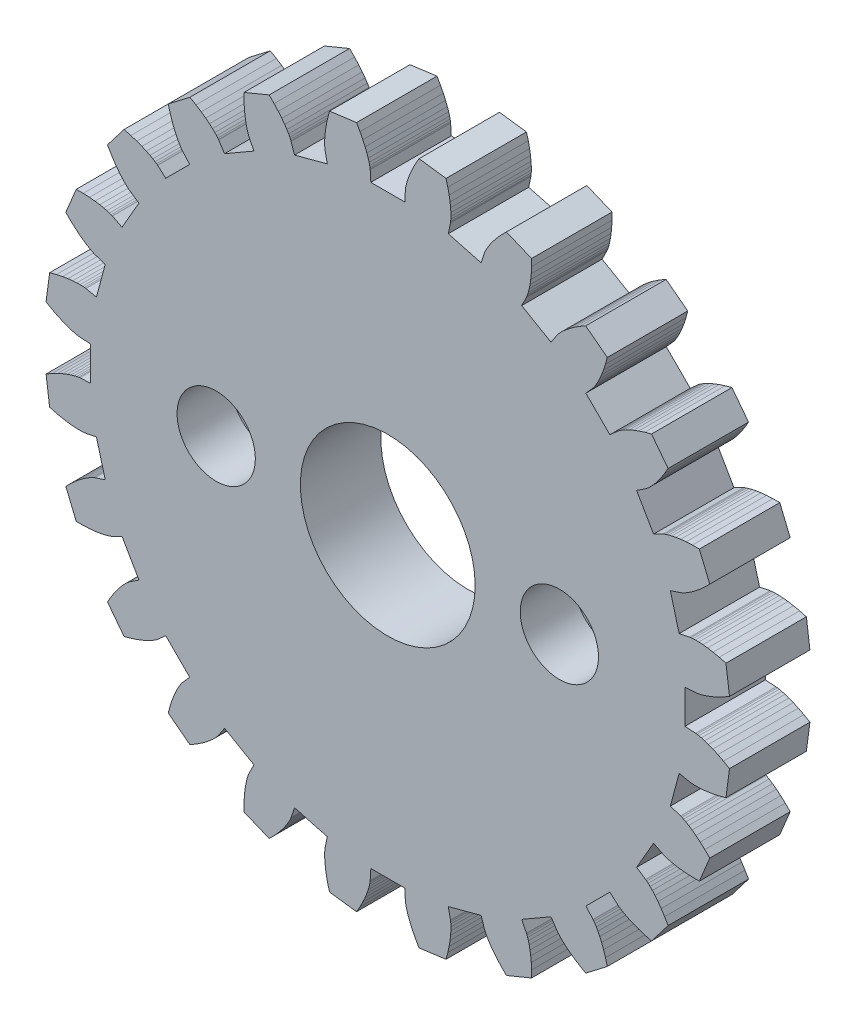
from build123d import *

# Parameters (mm, degrees)
MAIN_GEAR_BODY_DEPTH      = 3
SCALE1_SCALE              = 1.25
SKETCH1_R                 = 4.075
SKETCH1_R_2               = 1.15
SERVO_CLEARANCE_DEPTH     = 4.75
SKETCH2_R                 = 1.825
BOLT_HEAD_CLEARANCE_DEPTH = 2.5


with BuildPart() as part:
    # Model → Main Gear Body (new body)
    with BuildSketch(Plane.XY):
        Polygon((11.481280763, -0.655890262), (11.081931867, -0.633076687), (11.081931867, 0.633076687), (11.481280763, 0.655890262), (11.494959484, 0.657119822), (11.535795525, 0.662587053), (11.603342457, 0.674939875), (11.696960474, 0.69678954), (11.81581907, 0.730698092), (11.958900465, 0.779166001), (12.125003794, 0.844620031), (12.312750022, 0.929401369), (12.520587586, 1.035754071), (12.746798737, 1.165813859), (12.614196933, 2.173024562), (12.36203179, 2.240104916), (12.133750014, 2.289041418), (11.930458058, 2.322341602), (11.753073814, 2.342574636), (11.602323381, 2.352358851), (11.478738615, 2.354349128), (11.382655444, 2.351224158), (11.314212973, 2.345673635), (11.273353363, 2.34038543), (11.259822499, 2.338032781), (10.868176499, 2.256709902), (10.540471892, 3.479720146), (10.920308717, 3.605115467), (10.933203113, 3.609843444), (10.971232676, 3.625693529), (11.033280856, 3.655107871), (11.118053808, 3.700443153), (11.224086216, 3.763959167), (11.349747813, 3.847807762), (11.493250558, 3.954022205), (11.652656464, 4.084506989), (11.82588603, 4.24102813), (12.010727273, 4.425203993), (11.621958453, 5.36377495), (11.361023956, 5.363304455), (11.127854994, 5.351489815), (10.922871322, 5.331039494), (10.746294605, 5.304672682), (10.598148527, 5.275106425), (10.478259688, 5.245042794), (10.386259274, 5.21715615), (10.321585504, 5.194080542), (10.28348684, 5.178397283), (10.27102594, 5.172622753), (9.913772864, 4.99270544), (9.280696176, 6.089226427), (9.615135678, 6.30865801), (9.626367017, 6.316562201), (9.658998451, 6.341714983), (9.711319399, 6.386186306), (9.781470148, 6.45191768), (9.867450435, 6.540712645), (9.967128604, 6.654227783), (10.078251291, 6.7939643), (10.198453625, 6.961260207), (10.325269884, 7.157283131), (10.456144594, 7.383023787), (9.837702711, 8.18899294), (9.585781114, 8.121003659), (9.363615046, 8.049243025), (9.170908956, 7.976435853), (9.007173178, 7.905266052), (8.871727365, 7.838364214), (8.76370468, 7.778295462), (8.682056698, 7.727547573), (8.625559041, 7.688519444), (8.592817683, 7.663509918), (8.582275936, 7.654707033), (8.28376199, 7.388456353), (7.388456353, 8.28376199), (7.654707033, 8.582275936), (7.663509918, 8.592817683), (7.688519444, 8.625559041), (7.727547573, 8.682056698), (7.778295462, 8.76370468), (7.838364214, 8.871727365), (7.905266052, 9.007173178), (7.976435853, 9.170908956), (8.049243025, 9.363615046), (8.121003659, 9.585781114), (8.18899294, 9.837702711), (7.383023787, 10.456144594), (7.157283131, 10.325269884), (6.961260207, 10.198453625), (6.7939643, 10.078251291), (6.654227783, 9.967128604), (6.540712645, 9.867450435), (6.45191768, 9.781470148), (6.386186306, 9.711319399), (6.341714983, 9.658998451), (6.316562201, 9.626367017), (6.30865801, 9.615135678), (6.089226427, 9.280696176), (4.99270544, 9.913772864), (5.172622753, 10.27102594), (5.178397283, 10.28348684), (5.194080542, 10.321585504), (5.21715615, 10.386259274), (5.245042794, 10.478259688), (5.275106425, 10.598148527), (5.304672682, 10.746294605), (5.331039494, 10.922871322), (5.351489815, 11.127854994), (5.363304455, 11.361023956), (5.36377495, 11.621958453), (4.425203993, 12.010727273), (4.24102813, 11.82588603), (4.084506989, 11.652656464), (3.954022205, 11.493250558), (3.847807762, 11.349747813), (3.763959167, 11.224086216), (3.700443153, 11.118053808), (3.655107871, 11.033280856), (3.625693529, 10.971232676), (3.609843444, 10.933203113), (3.605115467, 10.920308717), (3.479720146, 10.540471892), (2.256709902, 10.868176499), (2.338032781, 11.259822499), (2.34038543, 11.273353363), (2.345673635, 11.314212973), (2.351224158, 11.382655444), (2.354349128, 11.478738615), (2.352358851, 11.602323381), (2.342574636, 11.753073814), (2.322341602, 11.930458058), (2.289041418, 12.133750014), (2.240104916, 12.36203179), (2.173024562, 12.614196933), (1.165813859, 12.746798737), (1.035754071, 12.520587586), (0.929401369, 12.312750022), (0.844620031, 12.125003794), (0.779166001, 11.958900465), (0.730698092, 11.81581907), (0.69678954, 11.696960474), (0.674939875, 11.603342457), (0.662587053, 11.535795525), (0.657119822, 11.494959484), (0.655890262, 11.481280763), (0.633076687, 11.081931867), (-0.633076687, 11.081931867), (-0.655890262, 11.481280763), (-0.657119822, 11.494959484), (-0.662587053, 11.535795525), (-0.674939875, 11.603342457), (-0.69678954, 11.696960474), (-0.730698092, 11.81581907), (-0.779166001, 11.958900465), (-0.844620031, 12.125003794), (-0.929401369, 12.312750022), (-1.035754071, 12.520587586), (-1.165813859, 12.746798737), (-2.173024562, 12.614196933), (-2.240104916, 12.36203179), (-2.289041418, 12.133750014), (-2.322341602, 11.930458058), (-2.342574636, 11.753073814), (-2.352358851, 11.602323381), (-2.354349128, 11.478738615), (-2.351224158, 11.382655444), (-2.345673635, 11.314212973), (-2.34038543, 11.273353363), (-2.338032781, 11.259822499), (-2.256709902, 10.868176499), (-3.479720146, 10.540471892), (-3.605115467, 10.920308717), (-3.609843444, 10.933203113), (-3.625693529, 10.971232676), (-3.655107871, 11.033280856), (-3.700443153, 11.118053808), (-3.763959167, 11.224086216), (-3.847807762, 11.349747813), (-3.954022205, 11.493250558), (-4.084506989, 11.652656464), (-4.24102813, 11.82588603), (-4.425203993, 12.010727273), (-5.36377495, 11.621958453), (-5.363304455, 11.361023956), (-5.351489815, 11.127854994), (-5.331039494, 10.922871322), (-5.304672682, 10.746294605), (-5.275106425, 10.598148527), (-5.245042794, 10.478259688), (-5.21715615, 10.386259274), (-5.194080542, 10.321585504), (-5.178397283, 10.28348684), (-5.172622753, 10.27102594), (-4.99270544, 9.913772864), (-6.089226427, 9.280696176), (-6.30865801, 9.615135678), (-6.316562201, 9.626367017), (-6.341714983, 9.658998451), (-6.386186306, 9.711319399), (-6.45191768, 9.781470148), (-6.540712645, 9.867450435), (-6.654227783, 9.967128604), (-6.7939643, 10.078251291), (-6.961260207, 10.198453625), (-7.157283131, 10.325269884), (-7.383023787, 10.456144594), (-8.18899294, 9.837702711), (-8.121003659, 9.585781114), (-8.049243025, 9.363615046), (-7.976435853, 9.170908956), (-7.905266052, 9.007173178), (-7.838364214, 8.871727365), (-7.778295462, 8.76370468), (-7.727547573, 8.682056698), (-7.688519444, 8.625559041), (-7.663509918, 8.592817683), (-7.654707033, 8.582275936), (-7.388456353, 8.28376199), (-8.28376199, 7.388456353), (-8.582275936, 7.654707033), (-8.592817683, 7.663509918), (-8.625559041, 7.688519444), (-8.682056698, 7.727547573), (-8.76370468, 7.778295462), (-8.871727365, 7.838364214), (-9.007173178, 7.905266052), (-9.170908956, 7.976435853), (-9.363615046, 8.049243025), (-9.585781114, 8.121003659), (-9.837702711, 8.18899294), (-10.456144594, 7.383023787), (-10.325269884, 7.157283131), (-10.198453625, 6.961260207), (-10.078251291, 6.7939643), (-9.967128604, 6.654227783), (-9.867450435, 6.540712645), (-9.781470148, 6.45191768), (-9.711319399, 6.386186306), (-9.658998451, 6.341714983), (-9.626367017, 6.316562201), (-9.615135678, 6.30865801), (-9.280696176, 6.089226427), (-9.913772864, 4.99270544), (-10.27102594, 5.172622753), (-10.28348684, 5.178397283), (-10.321585504, 5.194080542), (-10.386259274, 5.21715615), (-10.478259688, 5.245042794), (-10.598148527, 5.275106425), (-10.746294605, 5.304672682), (-10.922871322, 5.331039494), (-11.127854994, 5.351489815), (-11.361023956, 5.363304455), (-11.621958453, 5.36377495), (-12.010727273, 4.425203993), (-11.82588603, 4.24102813), (-11.652656464, 4.084506989), (-11.493250558, 3.954022205), (-11.349747813, 3.847807762), (-11.224086216, 3.763959167), (-11.118053808, 3.700443153), (-11.033280856, 3.655107871), (-10.971232676, 3.625693529), (-10.933203113, 3.609843444), (-10.920308717, 3.605115467), (-10.540471892, 3.479720146), (-10.868176499, 2.256709902), (-11.259822499, 2.338032781), (-11.273353363, 2.34038543), (-11.314212973, 2.345673635), (-11.382655444, 2.351224158), (-11.478738615, 2.354349128), (-11.602323381, 2.352358851), (-11.753073814, 2.342574636), (-11.930458058, 2.322341602), (-12.133750014, 2.289041418), (-12.36203179, 2.240104916), (-12.614196933, 2.173024562), (-12.746798737, 1.165813859), (-12.520587586, 1.035754071), (-12.312750022, 0.929401369), (-12.125003794, 0.844620031), (-11.958900465, 0.779166001), (-11.81581907, 0.730698092), (-11.696960474, 0.69678954), (-11.603342457, 0.674939875), (-11.535795525, 0.662587053), (-11.494959484, 0.657119822), (-11.481280763, 0.655890262), (-11.081931867, 0.633076687), (-11.081931867, -0.633076687), (-11.481280763, -0.655890262), (-11.494959484, -0.657119822), (-11.535795525, -0.662587053), (-11.603342457, -0.674939875), (-11.696960474, -0.69678954), (-11.81581907, -0.730698092), (-11.958900465, -0.779166001), (-12.125003794, -0.844620031), (-12.312750022, -0.929401369), (-12.520587586, -1.035754071), (-12.746798737, -1.165813859), (-12.614196933, -2.173024562), (-12.36203179, -2.240104916), (-12.133750014, -2.289041418), (-11.930458058, -2.322341602), (-11.753073814, -2.342574636), (-11.602323381, -2.352358851), (-11.478738615, -2.354349128), (-11.382655444, -2.351224158), (-11.314212973, -2.345673635), (-11.273353363, -2.34038543), (-11.259822499, -2.338032781), (-10.868176499, -2.256709902), (-10.540471892, -3.479720146), (-10.920308717, -3.605115467), (-10.933203113, -3.609843444), (-10.971232676, -3.625693529), (-11.033280856, -3.655107871), (-11.118053808, -3.700443153), (-11.224086216, -3.763959167), (-11.349747813, -3.847807762), (-11.493250558, -3.954022205), (-11.652656464, -4.084506989), (-11.82588603, -4.24102813), (-12.010727273, -4.425203993), (-11.621958453, -5.36377495), (-11.361023956, -5.363304455), (-11.127854994, -5.351489815), (-10.922871322, -5.331039494), (-10.746294605, -5.304672682), (-10.598148527, -5.275106425), (-10.478259688, -5.245042794), (-10.386259274, -5.21715615), (-10.321585504, -5.194080542), (-10.28348684, -5.178397283), (-10.27102594, -5.172622753), (-9.913772864, -4.99270544), (-9.280696176, -6.089226427), (-9.615135678, -6.30865801), (-9.626367017, -6.316562201), (-9.658998451, -6.341714983), (-9.711319399, -6.386186306), (-9.781470148, -6.45191768), (-9.867450435, -6.540712645), (-9.967128604, -6.654227783), (-10.078251291, -6.7939643), (-10.198453625, -6.961260207), (-10.325269884, -7.157283131), (-10.456144594, -7.383023787), (-9.837702711, -8.18899294), (-9.585781114, -8.121003659), (-9.363615046, -8.049243025), (-9.170908956, -7.976435853), (-9.007173178, -7.905266052), (-8.871727365, -7.838364214), (-8.76370468, -7.778295462), (-8.682056698, -7.727547573), (-8.625559041, -7.688519444), (-8.592817683, -7.663509918), (-8.582275936, -7.654707033), (-8.28376199, -7.388456353), (-7.388456353, -8.28376199), (-7.654707033, -8.582275936), (-7.663509918, -8.592817683), (-7.688519444, -8.625559041), (-7.727547573, -8.682056698), (-7.778295462, -8.76370468), (-7.838364214, -8.871727365), (-7.905266052, -9.007173178), (-7.976435853, -9.170908956), (-8.049243025, -9.363615046), (-8.121003659, -9.585781114), (-8.18899294, -9.837702711), (-7.383023787, -10.456144594), (-7.157283131, -10.325269884), (-6.961260207, -10.198453625), (-6.7939643, -10.078251291), (-6.654227783, -9.967128604), (-6.540712645, -9.867450435), (-6.45191768, -9.781470148), (-6.386186306, -9.711319399), (-6.341714983, -9.658998451), (-6.316562201, -9.626367017), (-6.30865801, -9.615135678), (-6.089226427, -9.280696176), (-4.99270544, -9.913772864), (-5.172622753, -10.27102594), (-5.178397283, -10.28348684), (-5.194080542, -10.321585504), (-5.21715615, -10.386259274), (-5.245042794, -10.478259688), (-5.275106425, -10.598148527), (-5.304672682, -10.746294605), (-5.331039494, -10.922871322), (-5.351489815, -11.127854994), (-5.363304455, -11.361023956), (-5.36377495, -11.621958453), (-4.425203993, -12.010727273), (-4.24102813, -11.82588603), (-4.084506989, -11.652656464), (-3.954022205, -11.493250558), (-3.847807762, -11.349747813), (-3.763959167, -11.224086216), (-3.700443153, -11.118053808), (-3.655107871, -11.033280856), (-3.625693529, -10.971232676), (-3.609843444, -10.933203113), (-3.605115467, -10.920308717), (-3.479720146, -10.540471892), (-2.256709902, -10.868176499), (-2.338032781, -11.259822499), (-2.34038543, -11.273353363), (-2.345673635, -11.314212973), (-2.351224158, -11.382655444), (-2.354349128, -11.478738615), (-2.352358851, -11.602323381), (-2.342574636, -11.753073814), (-2.322341602, -11.930458058), (-2.289041418, -12.133750014), (-2.240104916, -12.36203179), (-2.173024562, -12.614196933), (-1.165813859, -12.746798737), (-1.035754071, -12.520587586), (-0.929401369, -12.312750022), (-0.844620031, -12.125003794), (-0.779166001, -11.958900465), (-0.730698092, -11.81581907), (-0.69678954, -11.696960474), (-0.674939875, -11.603342457), (-0.662587053, -11.535795525), (-0.657119822, -11.494959484), (-0.655890262, -11.481280763), (-0.633076687, -11.081931867), (0.633076687, -11.081931867), (0.655890262, -11.481280763), (0.657119822, -11.494959484), (0.662587053, -11.535795525), (0.674939875, -11.603342457), (0.69678954, -11.696960474), (0.730698092, -11.81581907), (0.779166001, -11.958900465), (0.844620031, -12.125003794), (0.929401369, -12.312750022), (1.035754071, -12.520587586), (1.165813859, -12.746798737), (2.173024562, -12.614196933), (2.240104916, -12.36203179), (2.289041418, -12.133750014), (2.322341602, -11.930458058), (2.342574636, -11.753073814), (2.352358851, -11.602323381), (2.354349128, -11.478738615), (2.351224158, -11.382655444), (2.345673635, -11.314212973), (2.34038543, -11.273353363), (2.338032781, -11.259822499), (2.256709902, -10.868176499), (3.479720146, -10.540471892), (3.605115467, -10.920308717), (3.609843444, -10.933203113), (3.625693529, -10.971232676), (3.655107871, -11.033280856), (3.700443153, -11.118053808), (3.763959167, -11.224086216), (3.847807762, -11.349747813), (3.954022205, -11.493250558), (4.084506989, -11.652656464), (4.24102813, -11.82588603), (4.425203993, -12.010727273), (5.36377495, -11.621958453), (5.363304455, -11.361023956), (5.351489815, -11.127854994), (5.331039494, -10.922871322), (5.304672682, -10.746294605), (5.275106425, -10.598148527), (5.245042794, -10.478259688), (5.21715615, -10.386259274), (5.194080542, -10.321585504), (5.178397283, -10.28348684), (5.172622753, -10.27102594), (4.99270544, -9.913772864), (6.089226427, -9.280696176), (6.30865801, -9.615135678), (6.316562201, -9.626367017), (6.341714983, -9.658998451), (6.386186306, -9.711319399), (6.45191768, -9.781470148), (6.540712645, -9.867450435), (6.654227783, -9.967128604), (6.7939643, -10.078251291), (6.961260207, -10.198453625), (7.157283131, -10.325269884), (7.383023787, -10.456144594), (8.18899294, -9.837702711), (8.121003659, -9.585781114), (8.049243025, -9.363615046), (7.976435853, -9.170908956), (7.905266052, -9.007173178), (7.838364214, -8.871727365), (7.778295462, -8.76370468), (7.727547573, -8.682056698), (7.688519444, -8.625559041), (7.663509918, -8.592817683), (7.654707033, -8.582275936), (7.388456353, -8.28376199), (8.28376199, -7.388456353), (8.582275936, -7.654707033), (8.592817683, -7.663509918), (8.625559041, -7.688519444), (8.682056698, -7.727547573), (8.76370468, -7.778295462), (8.871727365, -7.838364214), (9.007173178, -7.905266052), (9.170908956, -7.976435853), (9.363615046, -8.049243025), (9.585781114, -8.121003659), (9.837702711, -8.18899294), (10.456144594, -7.383023787), (10.325269884, -7.157283131), (10.198453625, -6.961260207), (10.078251291, -6.7939643), (9.967128604, -6.654227783), (9.867450435, -6.540712645), (9.781470148, -6.45191768), (9.711319399, -6.386186306), (9.658998451, -6.341714983), (9.626367017, -6.316562201), (9.615135678, -6.30865801), (9.280696176, -6.089226427), (9.913772864, -4.99270544), (10.27102594, -5.172622753), (10.28348684, -5.178397283), (10.321585504, -5.194080542), (10.386259274, -5.21715615), (10.478259688, -5.245042794), (10.598148527, -5.275106425), (10.746294605, -5.304672682), (10.922871322, -5.331039494), (11.127854994, -5.351489815), (11.361023956, -5.363304455), (11.621958453, -5.36377495), (12.010727273, -4.425203993), (11.82588603, -4.24102813), (11.652656464, -4.084506989), (11.493250558, -3.954022205), (11.349747813, -3.847807762), (11.224086216, -3.763959167), (11.118053808, -3.700443153), (11.033280856, -3.655107871), (10.971232676, -3.625693529), (10.933203113, -3.609843444), (10.920308717, -3.605115467), (10.540471892, -3.479720146), (10.868176499, -2.256709902), (11.259822499, -2.338032781), (11.273353363, -2.34038543), (11.314212973, -2.345673635), (11.382655444, -2.351224158), (11.478738615, -2.354349128), (11.602323381, -2.352358851), (11.753073814, -2.342574636), (11.930458058, -2.322341602), (12.133750014, -2.289041418), (12.36203179, -2.240104916), (12.614196933, -2.173024562), (12.746798737, -1.165813859), (12.520587586, -1.035754071), (12.312750022, -0.929401369), (12.125003794, -0.844620031), (11.958900465, -0.779166001), (11.81581907, -0.730698092), (11.696960474, -0.69678954), (11.603342457, -0.674939875), (11.535795525, -0.662587053), (11.494959484, -0.657119822), align=None)
    extrude(amount=MAIN_GEAR_BODY_DEPTH)


with BuildPart() as part_1:
    # Scale1: scaled about (0, 0, 1.5)
    add(part.part.scale(SCALE1_SCALE).moved(Location((0, 0, -0.375))))

    # Sketch1 → Servo Clearance (cut, through all)
    with BuildSketch(Plane.XY.offset(3.375)):
        Circle(SKETCH1_R)
        with Locations((-8, 0)):
            Circle(SKETCH1_R_2)
        with Locations((8, 0)):
            Circle(SKETCH1_R_2)
    extrude(amount=-SERVO_CLEARANCE_DEPTH, mode=Mode.SUBTRACT)

    # Sketch2 → Bolt Head Clearance (cut)
    with BuildSketch(Plane.XY.offset(3.375)):
        with Locations((8, 0)):
            Circle(SKETCH2_R)
        with Locations((-8, 0)):
            Circle(SKETCH2_R)
    extrude(amount=-BOLT_HEAD_CLEARANCE_DEPTH, mode=Mode.SUBTRACT)


solid = part_1.part
